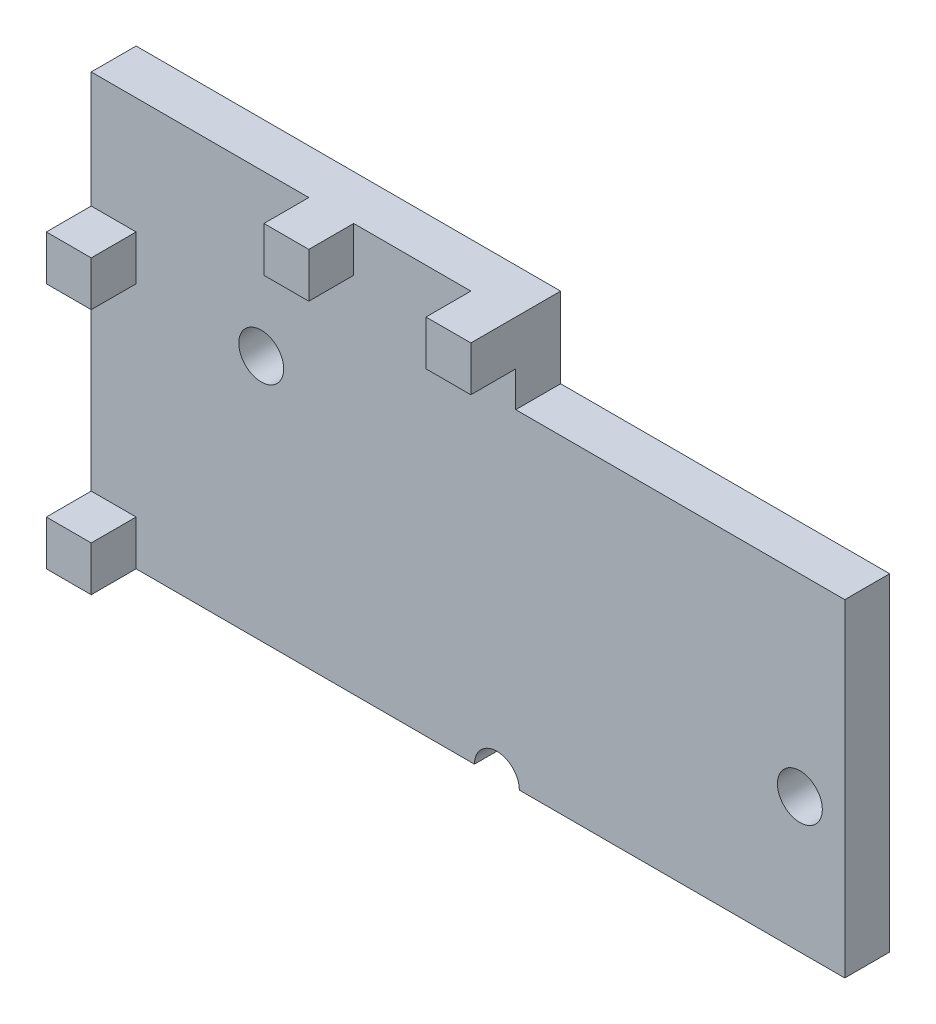
from build123d import *

# Parameters (mm, degrees)
SKETCH1_R             = 0.5
FRONT_FACE_EXT_DEPTH  = 1
SKETCH2_W             = 1
SKETCH2_H             = 6.5
LENGTH_EXTRUDE1_DEPTH = 1.7874
SKETCH3_W             = 1
SKETCH3_H             = 1
BOSS_EXTRUDE2_DEPTH   = 1
SKETCH4_W             = 9.4574
SKETCH4_H             = 1
HEIGHT_EXTRUDE3_DEPTH = 2.5874
SKETCH5_W             = 1
SKETCH5_H             = 1
BOSS_EXTRUDE4_DEPTH   = 1
SKETCH6_W             = 7.33
SKETCH6_H             = 1
BOSS_EXTRUDE5_DEPTH   = 0.8


with BuildPart() as part:
    # Sketch1 → Front Face Ext (new body)
    with BuildSketch(Plane.XY):
        with BuildLine():
            Line((-0.75, -3.25), (-7.5, -3.25))
            Line((-7.5, -3.25), (-7.5, 3.25))
            Line((-7.5, 3.25), (7.5, 3.25))
            Line((7.5, 3.25), (7.5, -3.25))
            Line((7.5, -3.25), (0.25, -3.25))
            ThreePointArc((0.25, -3.25), (-0.25, -2.75), (-0.75, -3.25))
        make_face()
        with Locations((-5.5, 2.25)):
            Circle(SKETCH1_R, mode=Mode.SUBTRACT)
        with Locations((6.5, -0.25)):
            Circle(SKETCH1_R, mode=Mode.SUBTRACT)
    extrude(amount=FRONT_FACE_EXT_DEPTH)

    # Sketch2 → Length-Extrude1 (add)
    with BuildSketch(Plane.ZY.offset(7.5)):
        with Locations((0.5, 0)):
            Rectangle(SKETCH2_W, SKETCH2_H)
    extrude(amount=LENGTH_EXTRUDE1_DEPTH)

    # Sketch3 → Boss-Extrude2 (add)
    with BuildSketch(Plane.XY.offset(1)):
        with Locations((-8.7874, 2.75)):
            Rectangle(SKETCH3_W, SKETCH3_H)
        with Locations((-8.7874, -2.75)):
            Rectangle(SKETCH3_W, SKETCH3_H)
    extrude(amount=BOSS_EXTRUDE2_DEPTH)

    # Sketch4 → Height-Extrude3 (add)
    with BuildSketch(Plane(origin=(0, 3.25, 0), x_dir=(1, 0, 0), z_dir=(0, 1, 0))):
        with Locations((-4.5587, -0.5)):
            Rectangle(SKETCH4_W, SKETCH4_H)
    extrude(amount=HEIGHT_EXTRUDE3_DEPTH)

    # Sketch5 → Boss-Extrude4 (add)
    with BuildSketch(Plane.XY.offset(1)):
        with Locations((-0.33, 5.3374)):
            Rectangle(SKETCH5_W, SKETCH5_H)
        with Locations((-3.94, 5.3374)):
            Rectangle(SKETCH5_W, SKETCH5_H)
    extrude(amount=BOSS_EXTRUDE4_DEPTH)

    # Sketch6 → Boss-Extrude5 (add)
    with BuildSketch(Plane(origin=(0, 3.25, 0), x_dir=(1, 0, 0), z_dir=(0, 1, 0))):
        with Locations((3.835, -0.5)):
            Rectangle(SKETCH6_W, SKETCH6_H)
    extrude(amount=BOSS_EXTRUDE5_DEPTH)


solid = part.part
